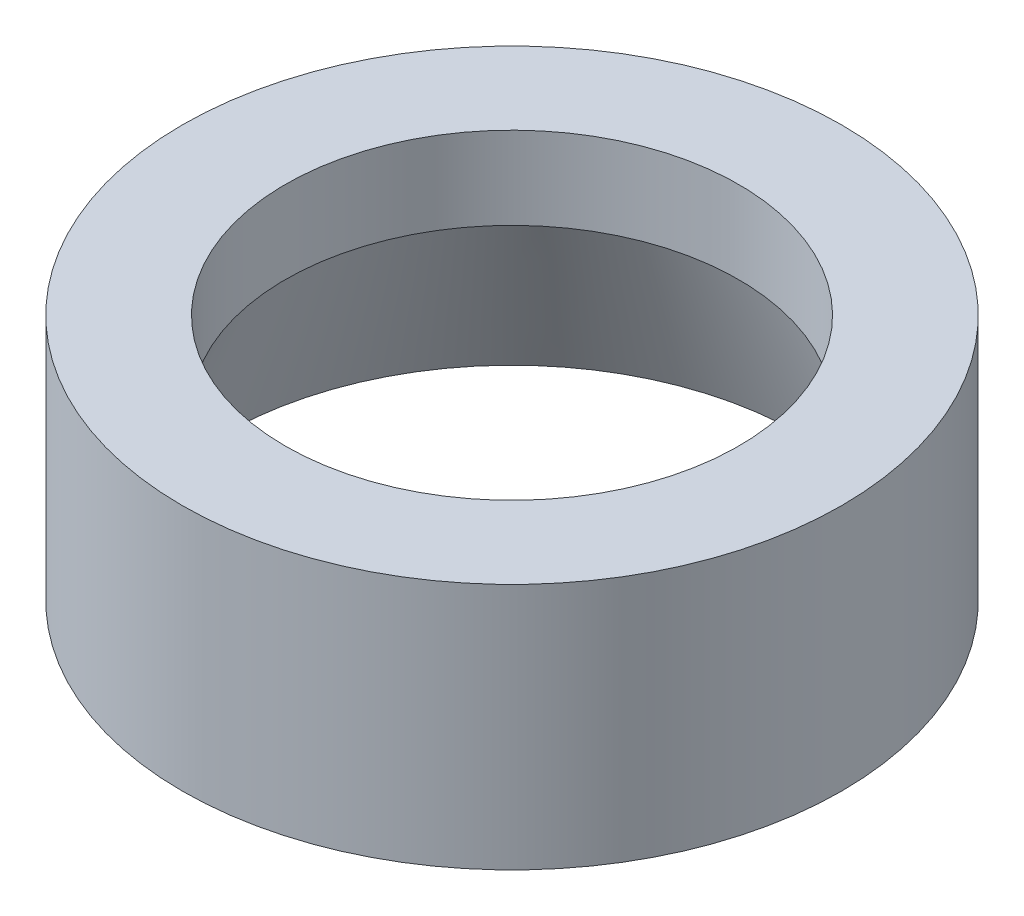
from build123d import *


with BuildPart() as part:
    # Sketch1 → Revolve1 (revolve)
    with BuildSketch(Plane.XY):
        Polygon((4, 1.5), (4, -1.5), (3.5, -1.5), (2.75, 0.5), (2.75, 1.5), align=None)
    revolve(axis=Axis((0, 1.5, 0), (0, -1, 0)))


solid = part.part
